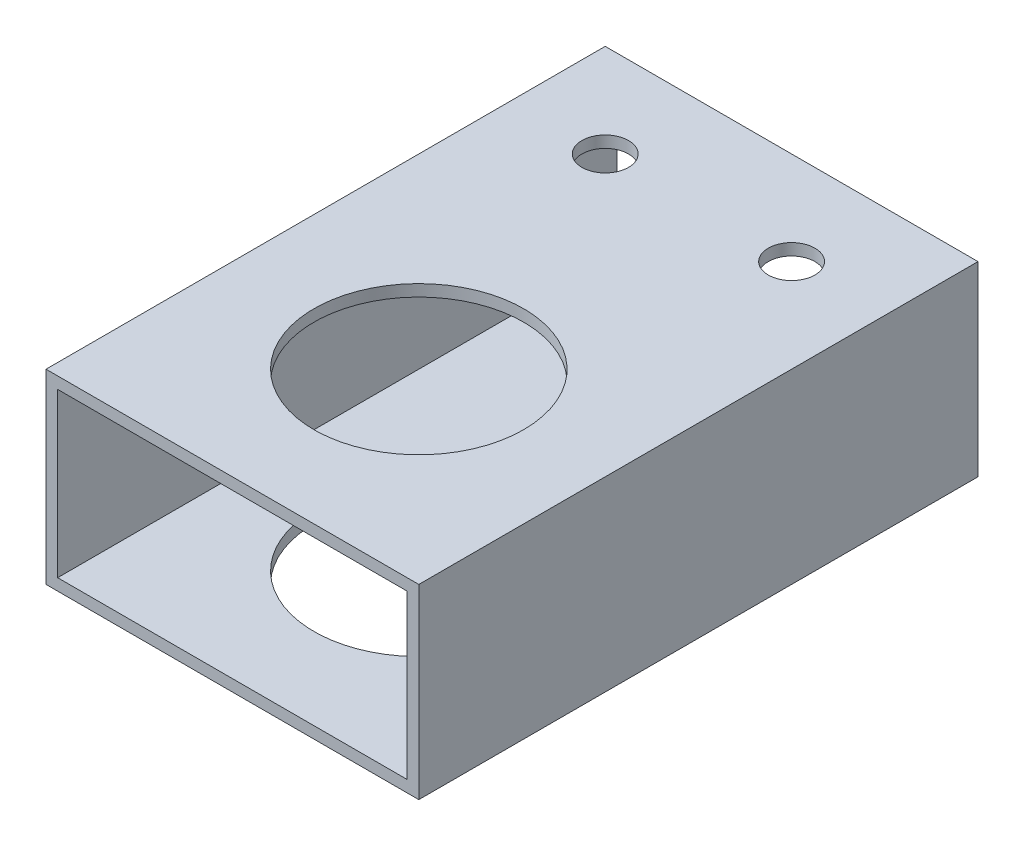
from build123d import *

# Parameters (mm, degrees)
SKETCH1_W           = 50.8
SKETCH1_H           = 25.4
SKETCH1_W_2         = 47.625
SKETCH1_H_2         = 22.225
BOSS_EXTRUDE1_DEPTH = 76.2
SKETCH2_R           = 14.2875
CUT_EXTRUDE1_DEPTH  = 26.4
SKETCH3_R           = 3.175
CUT_EXTRUDE2_DEPTH  = 25.4


with BuildPart() as part:
    # Sketch1 → Boss-Extrude1 (new body)
    with BuildSketch(Plane.XY):
        Rectangle(SKETCH1_W, SKETCH1_H)
        Rectangle(SKETCH1_W_2, SKETCH1_H_2, mode=Mode.SUBTRACT)
    extrude(amount=BOSS_EXTRUDE1_DEPTH)

    # Sketch2 → Cut-Extrude1 (cut, through all)
    with BuildSketch(Plane.XZ.offset(12.7)):
        with Locations((0, 50.8)):
            Circle(SKETCH2_R)
    extrude(amount=-CUT_EXTRUDE1_DEPTH, mode=Mode.SUBTRACT)

    # Sketch3 → Cut-Extrude2 (cut)
    with BuildSketch(Plane(origin=(0, 12.7, 0), x_dir=(1, 0, 0), z_dir=(0, 1, 0))):
        with Locations((12.7, -12.7)):
            Circle(SKETCH3_R)
        with Locations((-12.7, -12.7)):
            Circle(SKETCH3_R)
        with Locations((-12.7, 12.7)):
            Circle(SKETCH3_R)
        with Locations((12.7, 12.7)):
            Circle(SKETCH3_R)
        with Locations((12.7, 38.1)):
            Circle(SKETCH3_R)
        with Locations((-12.7, 38.1)):
            Circle(SKETCH3_R)
    extrude(amount=-CUT_EXTRUDE2_DEPTH, mode=Mode.SUBTRACT)


solid = part.part
